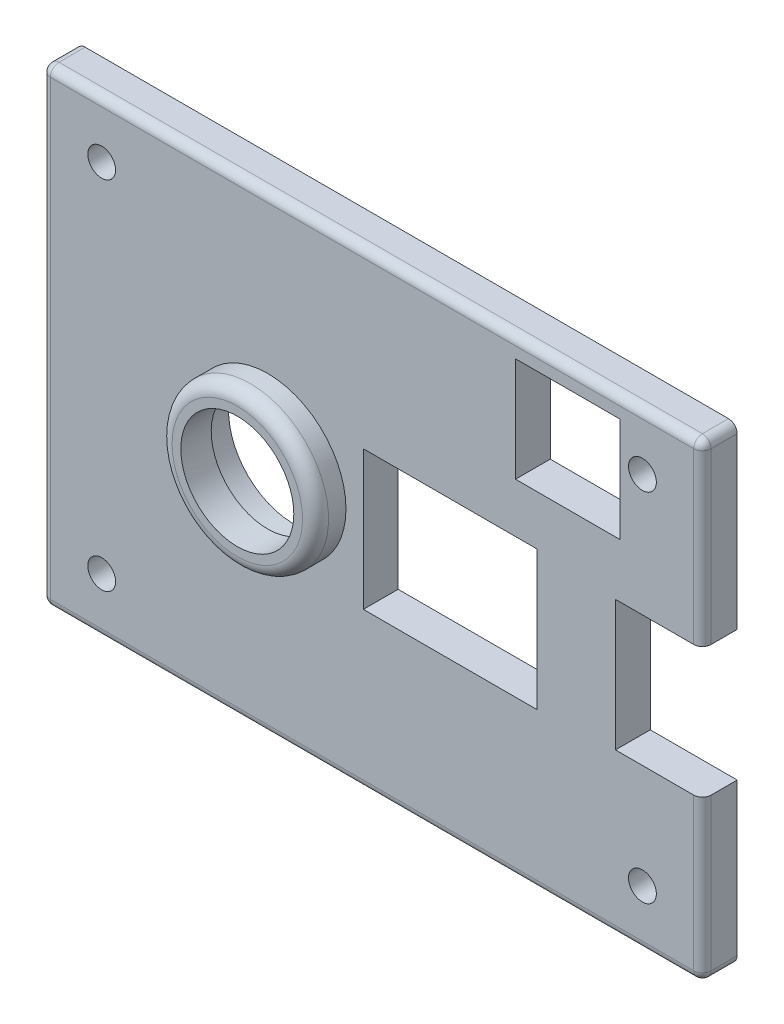
from build123d import *

# Parameters (mm, degrees)
ENCLOSURE_TOP_SKETCH_W          = 76
ENCLOSURE_TOP_SKETCH_H          = 54
ENCLOSURE_TOP_FEATURE_DEPTH     = 4
SCREW_HOLES_SKETCH_R            = 1.6
SCREW_HOLES_FEATURE_DEPTH       = 5
CAMERA_LIGHT_HOLE_SKETCH_R      = 7.5
CAMERA_LIGHT_HOLE_SKETCH_W      = 20
CAMERA_LIGHT_HOLE_SKETCH_H      = 16
CAMERA_LIGHT_HOLE_SKETCH_W_2    = 10
CAMERA_LIGHT_HOLE_SKETCH_H_2    = 15
CAMERA_LIGHT_HOLE_SKETCH_W_3    = 12
CAMERA_LIGHT_HOLE_SKETCH_H_3    = 12
CAMERA_LIGHT_HOLE_FEATURE_DEPTH = 5
FILTER_COVER_SKETCH_R           = 9
FILTER_COVER_FEATURE_DEPTH      = 3.5
FILTER_HOLE_SKETCH_R            = 6.5
FILTER_HOLE_CUT_DEPTH           = 3.5
FILLET6_R                       = 1.5
FILLET7_R                       = 1
FILLET8_R                       = 1
FILLET9_R                       = 1
FILLET10_R                      = 1
FILLET11_R                      = 1


with BuildPart() as part:
    # Enclosure Top Sketch → Enclosure Top Feature (new body)
    with BuildSketch(Plane.XY):
        Rectangle(ENCLOSURE_TOP_SKETCH_W, ENCLOSURE_TOP_SKETCH_H)
    extrude(amount=ENCLOSURE_TOP_FEATURE_DEPTH)

    # Screw Holes Sketch → Screw Holes Feature (cut, through all)
    with BuildSketch(Plane.XY.offset(4)):
        with Locations((-31.1, 20.5)):
            Circle(SCREW_HOLES_SKETCH_R)
        with Locations((31.1, 20.5)):
            Circle(SCREW_HOLES_SKETCH_R)
        with Locations((31.1, -20.5)):
            Circle(SCREW_HOLES_SKETCH_R)
        with Locations((-31.1, -20.5)):
            Circle(SCREW_HOLES_SKETCH_R)
    extrude(amount=-SCREW_HOLES_FEATURE_DEPTH, mode=Mode.SUBTRACT)

    # Camera + Light Hole Sketch → Camera _ Light Hole Feature (cut, through all)
    with BuildSketch(Plane.XY.offset(4)):
        with Locations((-13, -1)):
            Circle(CAMERA_LIGHT_HOLE_SKETCH_R)
        with Locations((9, -1)):
            Rectangle(CAMERA_LIGHT_HOLE_SKETCH_W, CAMERA_LIGHT_HOLE_SKETCH_H)
        with Locations((33, -1)):
            Rectangle(CAMERA_LIGHT_HOLE_SKETCH_W_2, CAMERA_LIGHT_HOLE_SKETCH_H_2)
        with Locations((22.5, 18.714)):
            Rectangle(CAMERA_LIGHT_HOLE_SKETCH_W_3, CAMERA_LIGHT_HOLE_SKETCH_H_3)
    extrude(amount=-CAMERA_LIGHT_HOLE_FEATURE_DEPTH, mode=Mode.SUBTRACT)

    # Filter Cover Sketch → Filter Cover Feature (add)
    with BuildSketch(Plane(origin=(0, 0, 4), x_dir=(-1, 0, 0), z_dir=(0, 0, -1))):
        with Locations((12, 0)):
            Circle(FILTER_COVER_SKETCH_R)
    extrude(amount=-FILTER_COVER_FEATURE_DEPTH)

    # Filter Hole Sketch → Filter Hole Cut (cut)
    with BuildSketch(Plane.XY.offset(4)):
        with Locations((-12, 0)):
            Circle(FILTER_HOLE_SKETCH_R)
    extrude(amount=FILTER_HOLE_CUT_DEPTH, mode=Mode.SUBTRACT)

    # Fillet6
    fillet6_edges = [part.edges().sort_by_distance(p)[0] for p in [
        (-3, 0, 7.5),
    ]]
    fillet(fillet6_edges, radius=FILLET6_R)

    # Fillet7
    fillet7_edges = [part.edges().sort_by_distance(p)[0] for p in [
        (0, 27, 4),
    ]]
    fillet(fillet7_edges, radius=FILLET7_R)

    # Fillet8
    fillet8_edges = [part.edges().sort_by_distance(p)[0] for p in [
        (0, -27, 4),
    ]]
    fillet(fillet8_edges, radius=FILLET8_R)

    # Fillet9
    fillet9_edges = [part.edges().sort_by_distance(p)[0] for p in [
        (-38, 0, 4),
        (-38, 27, 1.5),
        (-38, 26.707106781, 3.707106781),
        (-38, -27, 1.5),
        (-38, -26.707106781, 3.707106781),
    ]]
    fillet(fillet9_edges, radius=FILLET9_R)

    # Fillet10
    fillet10_edges = [part.edges().sort_by_distance(p)[0] for p in [
        (38, 27, 1.5),
        (38, 26.707106781, 3.707106781),
        (38, 16.25, 4),
    ]]
    fillet(fillet10_edges, radius=FILLET10_R)

    # Fillet11
    fillet11_edges = [part.edges().sort_by_distance(p)[0] for p in [
        (38, -17.25, 4),
        (38, -27, 1.5),
        (38, -26.707106781, 3.707106781),
    ]]
    fillet(fillet11_edges, radius=FILLET11_R)


solid = part.part
